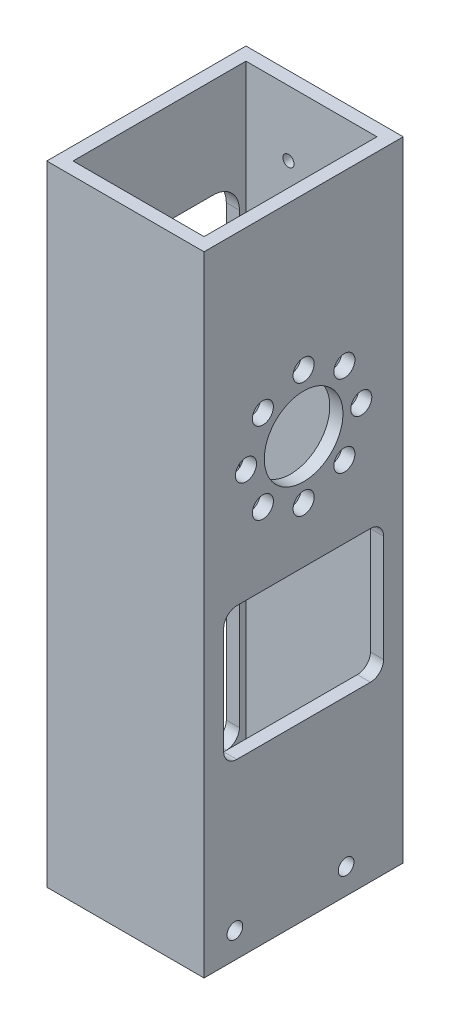
from build123d import *

# Parameters (mm, degrees)
SKETCH1_W                      = 38.1
SKETCH1_H                      = 48.26
SKETCH1_W_2                    = 31.75
SKETCH1_H_2                    = 41.91
BOSS_EXTRUDE1_DEPTH            = 152.4
SKETCH2_R                      = 1.89865
CUT_EXTRUDE1_DEPTH             = 35.925
CUT_EXTRUDE1_DEPTH_BACK        = 4.175
CUT_EXTRUDE3_DEPTH             = 3.175
CUT_EXTRUDE4_DEPTH             = 3.175
CUT_EXTRUDE5_REACH             = 36.925
SKETCH6_R                      = 9.525
SKETCH6_R_2                    = 2.5527
CUT_EXTRUDE6_DEPTH             = 3.175
F_6_32_TAPPED_HOLE2_D          = 2.7051
F_6_32_TAPPED_HOLE2_DEPTH      = 3.175
CUT_EXTRUDE7_REACH             = 40.1
CUT_EXTRUDE7_DIRECTION_2_DEPTH = 1
FILLET1_R                      = 3.175
FILLET2_R                      = 3.175
BOSS_EXTRUDE2_DEPTH            = 3.175
CUT_EXTRUDE8_REACH             = 40.1
FILLET3_R                      = 3.175
FILLET4_R                      = 3.175
FILLET5_R                      = 6.35
FILLET6_R                      = 6.35
BOSS_EXTRUDE3_DEPTH            = 3.175
CUT_EXTRUDE9_REACH             = 40.1
BOSS_EXTRUDE4_DEPTH            = 3.175
FILLET7_R                      = 3.175
FILLET8_R                      = 3.175
FILLET9_R                      = 3.175
FILLET10_R                     = 3.175
FILLET11_R                     = 6.35
FILLET12_R                     = 6.35


with BuildPart() as part:
    # Sketch1 → Boss-Extrude1 (new body)
    with BuildSketch(Plane(origin=(0, 0, 0), x_dir=(1, 0, 0), z_dir=(0, 1, 0))):
        Rectangle(SKETCH1_W, SKETCH1_H)
        Rectangle(SKETCH1_W_2, SKETCH1_H_2, mode=Mode.SUBTRACT)
    extrude(amount=BOSS_EXTRUDE1_DEPTH)

    # Sketch2 → Cut-Extrude1 (cut, two sides)
    with BuildSketch(Plane(origin=(-15.875, 0, 0), x_dir=(0, 0, -1), z_dir=(1, 0, 0))) as cut_extrude1_sk:
        with Locations((-16.645384182, 6.21538)):
            Circle(SKETCH2_R)
        with Locations((10.30030417, 6.18241423)):
            Circle(SKETCH2_R)
    extrude(amount=CUT_EXTRUDE1_DEPTH, mode=Mode.SUBTRACT)
    extrude(cut_extrude1_sk.sketch, amount=-CUT_EXTRUDE1_DEPTH_BACK, mode=Mode.SUBTRACT)

    # Sketch4 → Cut-Extrude3 (cut)
    with BuildSketch(Plane.ZY.offset(19.05)):
        with BuildLine():
            Line((16.1925, 10.16), (-16.1925, 10.16))
            ThreePointArc((-16.1925, 10.16), (-18.43756403, 11.08993597), (-19.3675, 13.335))
            Line((-19.3675, 13.335), (-19.3675, 64.135))
            ThreePointArc((-19.3675, 64.135), (-18.43756403, 66.38006403), (-16.1925, 67.31))
            Line((-16.1925, 67.31), (16.1925, 67.31))
            ThreePointArc((16.1925, 67.31), (18.43756403, 66.38006403), (19.3675, 64.135))
            Line((19.3675, 64.135), (19.3675, 13.335))
            ThreePointArc((19.3675, 13.335), (18.43756403, 11.08993597), (16.1925, 10.16))
        make_face()
    extrude(amount=-CUT_EXTRUDE3_DEPTH, mode=Mode.SUBTRACT)

    # Sketch5 → Cut-Extrude4 (cut)
    with BuildSketch(Plane(origin=(19.05, 0, 0), x_dir=(0, 0, -1), z_dir=(1, 0, 0))):
        with BuildLine():
            Line((16.1925, 67.31), (-16.1925, 67.31))
            ThreePointArc((-16.1925, 67.31), (-18.43756403, 66.38006403), (-19.3675, 64.135))
            Line((-19.3675, 64.135), (-19.3675, 45.085))
            ThreePointArc((-19.3675, 45.085), (-18.43756403, 42.83993597), (-16.1925, 41.91))
            Line((-16.1925, 41.91), (16.1925, 41.91))
            ThreePointArc((16.1925, 41.91), (18.43756403, 42.83993597), (19.3675, 45.085))
            Line((19.3675, 45.085), (19.3675, 64.135))
            ThreePointArc((19.3675, 64.135), (18.43756403, 66.38006403), (16.1925, 67.31))
        make_face()
    extrude(amount=-CUT_EXTRUDE4_DEPTH, mode=Mode.SUBTRACT)

    # Sketch6 → Cut-Extrude5 (cut, up to next)
    with BuildSketch(Plane(origin=(-15.875, 0, 0), x_dir=(0, 0, -1), z_dir=(1, 0, 0)), mode=Mode.PRIVATE) as cut_extrude5_sk1:
        with Locations((0, 101.6)):
            Circle(SKETCH6_R)
    cut_extrude5_tool1 = extrude(cut_extrude5_sk1.sketch, amount=CUT_EXTRUDE5_REACH, mode=Mode.PRIVATE) & part.part
    add(cut_extrude5_tool1.solids().sort_by_distance((-15.875, 101.6, 0))[0], mode=Mode.SUBTRACT)
    # Sketch6 → Cut-Extrude5 (cut, up to next)
    with BuildSketch(Plane(origin=(-15.875, 0, 0), x_dir=(0, 0, -1), z_dir=(1, 0, 0)), mode=Mode.PRIVATE) as cut_extrude5_sk2:
        with Locations((0, 87.63)):
            Circle(SKETCH6_R_2)
    cut_extrude5_tool2 = extrude(cut_extrude5_sk2.sketch, amount=CUT_EXTRUDE5_REACH, mode=Mode.PRIVATE) & part.part
    add(cut_extrude5_tool2.solids().sort_by_distance((-15.875, 87.63, 0))[0], mode=Mode.SUBTRACT)
    # Sketch6 → Cut-Extrude5 (cut, up to next)
    with BuildSketch(Plane(origin=(-15.875, 0, 0), x_dir=(0, 0, -1), z_dir=(1, 0, 0)), mode=Mode.PRIVATE) as cut_extrude5_sk3:
        with Locations((-9.878281733, 91.721718267)):
            Circle(SKETCH6_R_2)
    cut_extrude5_tool3 = extrude(cut_extrude5_sk3.sketch, amount=CUT_EXTRUDE5_REACH, mode=Mode.PRIVATE) & part.part
    add(cut_extrude5_tool3.solids().sort_by_distance((-15.875, 91.721718, 9.878282))[0], mode=Mode.SUBTRACT)
    # Sketch6 → Cut-Extrude5 (cut, up to next)
    with BuildSketch(Plane(origin=(-15.875, 0, 0), x_dir=(0, 0, -1), z_dir=(1, 0, 0)), mode=Mode.PRIVATE) as cut_extrude5_sk4:
        with Locations((-13.97, 101.6)):
            Circle(SKETCH6_R_2)
    cut_extrude5_tool4 = extrude(cut_extrude5_sk4.sketch, amount=CUT_EXTRUDE5_REACH, mode=Mode.PRIVATE) & part.part
    add(cut_extrude5_tool4.solids().sort_by_distance((-15.875, 101.6, 13.97))[0], mode=Mode.SUBTRACT)
    # Sketch6 → Cut-Extrude5 (cut, up to next)
    with BuildSketch(Plane(origin=(-15.875, 0, 0), x_dir=(0, 0, -1), z_dir=(1, 0, 0)), mode=Mode.PRIVATE) as cut_extrude5_sk5:
        with Locations((-9.878281733, 111.478281733)):
            Circle(SKETCH6_R_2)
    cut_extrude5_tool5 = extrude(cut_extrude5_sk5.sketch, amount=CUT_EXTRUDE5_REACH, mode=Mode.PRIVATE) & part.part
    add(cut_extrude5_tool5.solids().sort_by_distance((-15.875, 111.478282, 9.878282))[0], mode=Mode.SUBTRACT)
    # Sketch6 → Cut-Extrude5 (cut, up to next)
    with BuildSketch(Plane(origin=(-15.875, 0, 0), x_dir=(0, 0, -1), z_dir=(1, 0, 0)), mode=Mode.PRIVATE) as cut_extrude5_sk6:
        with Locations((0, 115.57)):
            Circle(SKETCH6_R_2)
    cut_extrude5_tool6 = extrude(cut_extrude5_sk6.sketch, amount=CUT_EXTRUDE5_REACH, mode=Mode.PRIVATE) & part.part
    add(cut_extrude5_tool6.solids().sort_by_distance((-15.875, 115.57, 0))[0], mode=Mode.SUBTRACT)
    # Sketch6 → Cut-Extrude5 (cut, up to next)
    with BuildSketch(Plane(origin=(-15.875, 0, 0), x_dir=(0, 0, -1), z_dir=(1, 0, 0)), mode=Mode.PRIVATE) as cut_extrude5_sk7:
        with Locations((9.878281733, 111.478281733)):
            Circle(SKETCH6_R_2)
    cut_extrude5_tool7 = extrude(cut_extrude5_sk7.sketch, amount=CUT_EXTRUDE5_REACH, mode=Mode.PRIVATE) & part.part
    add(cut_extrude5_tool7.solids().sort_by_distance((-15.875, 111.478282, -9.878282))[0], mode=Mode.SUBTRACT)
    # Sketch6 → Cut-Extrude5 (cut, up to next)
    with BuildSketch(Plane(origin=(-15.875, 0, 0), x_dir=(0, 0, -1), z_dir=(1, 0, 0)), mode=Mode.PRIVATE) as cut_extrude5_sk8:
        with Locations((13.97, 101.6)):
            Circle(SKETCH6_R_2)
    cut_extrude5_tool8 = extrude(cut_extrude5_sk8.sketch, amount=CUT_EXTRUDE5_REACH, mode=Mode.PRIVATE) & part.part
    add(cut_extrude5_tool8.solids().sort_by_distance((-15.875, 101.6, -13.97))[0], mode=Mode.SUBTRACT)
    # Sketch6 → Cut-Extrude5 (cut, up to next)
    with BuildSketch(Plane(origin=(-15.875, 0, 0), x_dir=(0, 0, -1), z_dir=(1, 0, 0)), mode=Mode.PRIVATE) as cut_extrude5_sk9:
        with Locations((9.878281733, 91.721718267)):
            Circle(SKETCH6_R_2)
    cut_extrude5_tool9 = extrude(cut_extrude5_sk9.sketch, amount=CUT_EXTRUDE5_REACH, mode=Mode.PRIVATE) & part.part
    add(cut_extrude5_tool9.solids().sort_by_distance((-15.875, 91.721718, -9.878282))[0], mode=Mode.SUBTRACT)

    # Sketch7 → Cut-Extrude6 (cut)
    with BuildSketch(Plane.ZY.offset(19.05)):
        with BuildLine():
            Line((-13.0175, 77.47), (13.0175, 77.47))
            ThreePointArc((13.0175, 77.47), (17.507628061, 79.329871939), (19.3675, 83.82))
            Line((19.3675, 83.82), (19.3675, 121.92))
            ThreePointArc((19.3675, 121.92), (17.507628061, 126.410128061), (13.0175, 128.27))
            Line((13.0175, 128.27), (-13.0175, 128.27))
            ThreePointArc((-13.0175, 128.27), (-17.507628061, 126.410128061), (-19.3675, 121.92))
            Line((-19.3675, 121.92), (-19.3675, 83.82))
            ThreePointArc((-19.3675, 83.82), (-17.507628061, 79.329871939), (-13.0175, 77.47))
        make_face()
    extrude(amount=-CUT_EXTRUDE6_DEPTH, mode=Mode.SUBTRACT)

    # #6-32 Tapped Hole2
    with Locations(Plane(origin=(5.579615818, 136.6393, -24.13), x_dir=(-1, 0, 0), z_dir=(0, 0, -1))):
        with Locations((0, 0), (11.159231636, 0)):
            Hole(F_6_32_TAPPED_HOLE2_D / 2, depth=F_6_32_TAPPED_HOLE2_DEPTH)

    # Sketch13 → Cut-Extrude7 (cut, up to next)
    with BuildSketch(Plane(origin=(19.05, 0, 0), x_dir=(0, 0, -1), z_dir=(1, 0, 0)), mode=Mode.PRIVATE) as cut_extrude7_sk1:
        Polygon((0, 78.486), (19.3675, 78.486), (19.3675, 64.135), (-19.3675, 64.135), (-19.3675, 78.486), align=None)
    cut_extrude7_tool1 = extrude(cut_extrude7_sk1.sketch, amount=-CUT_EXTRUDE7_REACH, mode=Mode.PRIVATE) & part.part
    add(cut_extrude7_tool1.solids().sort_by_distance((19.05, 71.3105, 0))[0], mode=Mode.SUBTRACT)

    # Sketch13 → Cut-Extrude7 direction 2 (cut)
    with BuildSketch(Plane(origin=(19.05, 0, 0), x_dir=(0, 0, -1), z_dir=(1, 0, 0))):
        Polygon((0, 78.486), (19.3675, 78.486), (19.3675, 64.135), (-19.3675, 64.135), (-19.3675, 78.486), align=None)
    extrude(amount=CUT_EXTRUDE7_DIRECTION_2_DEPTH, mode=Mode.SUBTRACT)

    # Fillet1
    fillet1_edges = [part.edges().sort_by_distance(p)[0] for p in [
        (17.4625, 78.486, -19.3675),
    ]]
    fillet(fillet1_edges, radius=FILLET1_R)

    # Fillet2
    fillet2_edges = [part.edges().sort_by_distance(p)[0] for p in [
        (17.4625, 78.486, 19.3675),
    ]]
    fillet(fillet2_edges, radius=FILLET2_R)

    # Sketch15 → Boss-Extrude2 (add)
    with BuildSketch(Plane.ZY.offset(19.05)):
        Polygon((0, 78.486), (-19.3675, 78.486), (-19.3675, 88.646), (0, 88.646), (19.3675, 88.646), (19.3675, 78.486), align=None)
    extrude(amount=-BOSS_EXTRUDE2_DEPTH)

    # Sketch16 → Cut-Extrude8 (cut, up to next)
    with BuildSketch(Plane.ZY.offset(19.05), mode=Mode.PRIVATE) as cut_extrude8_sk1:
        Polygon((0, 78.486), (19.3675, 78.486), (19.3675, 64.135), (-19.3675, 64.135), (-19.3675, 78.486), align=None)
    cut_extrude8_tool1 = extrude(cut_extrude8_sk1.sketch, amount=-CUT_EXTRUDE8_REACH, mode=Mode.PRIVATE) & part.part
    add(cut_extrude8_tool1.solids().sort_by_distance((-19.05, 71.3105, 0))[0], mode=Mode.SUBTRACT)

    # Fillet3
    fillet3_edges = [part.edges().sort_by_distance(p)[0] for p in [
        (-17.4625, 78.486, 19.3675),
    ]]
    fillet(fillet3_edges, radius=FILLET3_R)

    # Fillet4
    fillet4_edges = [part.edges().sort_by_distance(p)[0] for p in [
        (-17.4625, 78.486, -19.3675),
    ]]
    fillet(fillet4_edges, radius=FILLET4_R)

    # Fillet5
    fillet5_edges = [part.edges().sort_by_distance(p)[0] for p in [
        (-17.4625, 88.646, -19.3675),
    ]]
    fillet(fillet5_edges, radius=FILLET5_R)

    # Fillet6
    fillet6_edges = [part.edges().sort_by_distance(p)[0] for p in [
        (-17.4625, 88.646, 19.3675),
    ]]
    fillet(fillet6_edges, radius=FILLET6_R)

    # Sketch17 → Boss-Extrude3 (add)
    with BuildSketch(Plane.ZY.offset(19.05)):
        Polygon((0, 74.168), (19.3675, 74.168), (19.3675, 84.35471455), (-20.6375, 84.35471455), (-19.3675, 74.168), align=None)
    extrude(amount=-BOSS_EXTRUDE3_DEPTH)

    # Sketch18 → Cut-Extrude9 (cut, up to next)
    with BuildSketch(Plane.ZY.offset(19.05), mode=Mode.PRIVATE) as cut_extrude9_sk1:
        Polygon((0, 84.328), (-19.3675, 84.328), (-19.3675, 94.996), (19.3675, 94.996), (19.3675, 84.328), align=None)
    cut_extrude9_tool1 = extrude(cut_extrude9_sk1.sketch, amount=-CUT_EXTRUDE9_REACH, mode=Mode.PRIVATE) & part.part
    add(cut_extrude9_tool1.solids().sort_by_distance((-19.05, 89.662, 0))[0], mode=Mode.SUBTRACT)

    # Sketch19 → Boss-Extrude4 (add)
    with BuildSketch(Plane(origin=(19.05, 0, 0), x_dir=(0, 0, -1), z_dir=(1, 0, 0))):
        Polygon((0, 74.168), (19.3675, 74.168), (19.3675, 78.486), (-19.3675, 78.486), (-19.3675, 74.168), align=None)
    extrude(amount=-BOSS_EXTRUDE4_DEPTH)

    # Fillet7
    fillet7_edges = [part.edges().sort_by_distance(p)[0] for p in [
        (17.4625, 74.168, -19.3675),
    ]]
    fillet(fillet7_edges, radius=FILLET7_R)

    # Fillet8
    fillet8_edges = [part.edges().sort_by_distance(p)[0] for p in [
        (17.4625, 74.168, 19.3675),
    ]]
    fillet(fillet8_edges, radius=FILLET8_R)

    # Fillet9
    fillet9_edges = [part.edges().sort_by_distance(p)[0] for p in [
        (-17.4625, 74.168, 19.3675),
    ]]
    fillet(fillet9_edges, radius=FILLET9_R)

    # Fillet10
    fillet10_edges = [part.edges().sort_by_distance(p)[0] for p in [
        (-17.4625, 74.168, -19.3675),
    ]]
    fillet(fillet10_edges, radius=FILLET10_R)

    # Fillet11
    fillet11_edges = [part.edges().sort_by_distance(p)[0] for p in [
        (-17.4625, 84.328, -19.3675),
    ]]
    fillet(fillet11_edges, radius=FILLET11_R)

    # Fillet12
    fillet12_edges = [part.edges().sort_by_distance(p)[0] for p in [
        (-17.4625, 84.328, 19.3675),
    ]]
    fillet(fillet12_edges, radius=FILLET12_R)


solid = part.part
